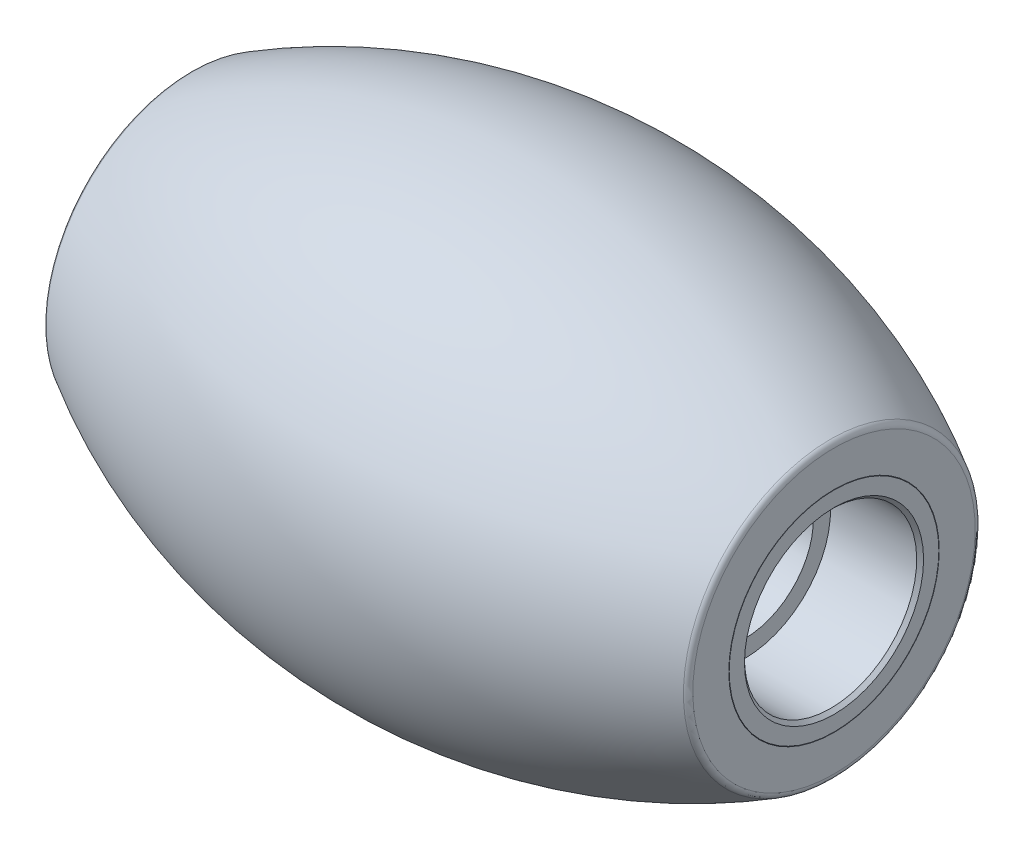
from build123d import *

# Parameters (mm, degrees)
CHANFREIN1_SIZE = 0.1
CONG_1_R        = 0.2


with BuildPart() as part:
    # Esquisse1 → Révolution1 (revolve)
    with BuildSketch(Plane.XY):
        with BuildLine():
            Line((9.35, 0), (9.35, 3.042819204))
            ThreePointArc((9.35, 3.042819204), (0, 5.75), (-9.35, 3.042819204))
            Line((-9.35, 3.042819204), (-9.35, 0))
            Line((-9.35, 0), (9.35, 0))
        make_face()
    revolve(axis=Axis((-9.35, 0, 0), (1, 0, 0)))

    # Esquisse2 → Enlèvement de matière-Révolution1 (revolve, cut)
    with BuildSketch(Plane.XY):
        Polygon((-9.35, 2.5), (-6.75, 2.5), (-6.75, 2), (6.75, 2), (6.75, 2.5), (9.35, 2.5), (9.35, 0), (-9.35, 0), align=None)
    revolve(axis=Axis((-9.35, 0, 0), (1, 0, 0)), mode=Mode.SUBTRACT)

    # Chanfrein1
    chanfrein1_edges = [part.edges().sort_by_distance(p)[0] for p in [
        (-9.35, -2.5, 0),
        (9.35, -2.5, 0),
    ]]
    chamfer(chanfrein1_edges, length=CHANFREIN1_SIZE)


with BuildPart() as body_2:
    # Esquisse4 → Révolution2 (revolve)
    with BuildSketch(Plane.XY):
        with BuildLine():
            Line((-9.35, 3.054647919), (-9.35, 4.213317324))
            ThreePointArc((-9.35, 4.213317324), (0, 6.75), (9.35, 4.213317324))
            Line((9.35, 4.213317324), (9.35, 3.054647919))
            ThreePointArc((9.35, 3.054647919), (0, 5.76), (-9.35, 3.054647919))
        make_face()
    revolve(axis=Axis((-9.35, 0, 0), (1, 0, 0)))

    # Congé1
    cong_1_edges = [body_2.edges().sort_by_distance(p)[0] for p in [
        (-9.35, -4.213317324, 0),
        (9.35, -4.213317324, 0),
    ]]
    fillet(cong_1_edges, radius=CONG_1_R)


solid = Compound([part.part, body_2.part])
